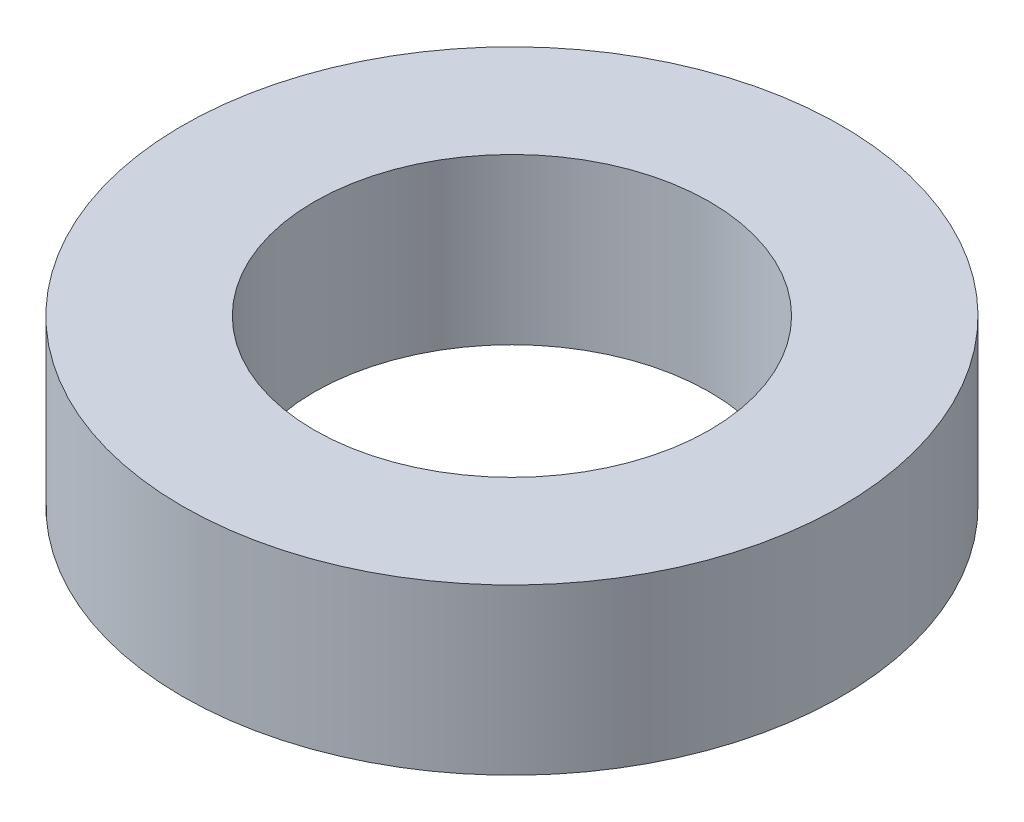
from build123d import *

# Parameters (mm, degrees)
SKETCH1_R           = 10
SKETCH1_R_2         = 6
BOSS_EXTRUDE1_DEPTH = 5


with BuildPart() as part:
    # Sketch1 → Boss-Extrude1 (new body)
    with BuildSketch(Plane(origin=(0, 0, 0), x_dir=(1, 0, 0), z_dir=(0, 1, 0))):
        Circle(SKETCH1_R)
        Circle(SKETCH1_R_2, mode=Mode.SUBTRACT)
    extrude(amount=BOSS_EXTRUDE1_DEPTH)


solid = part.part
